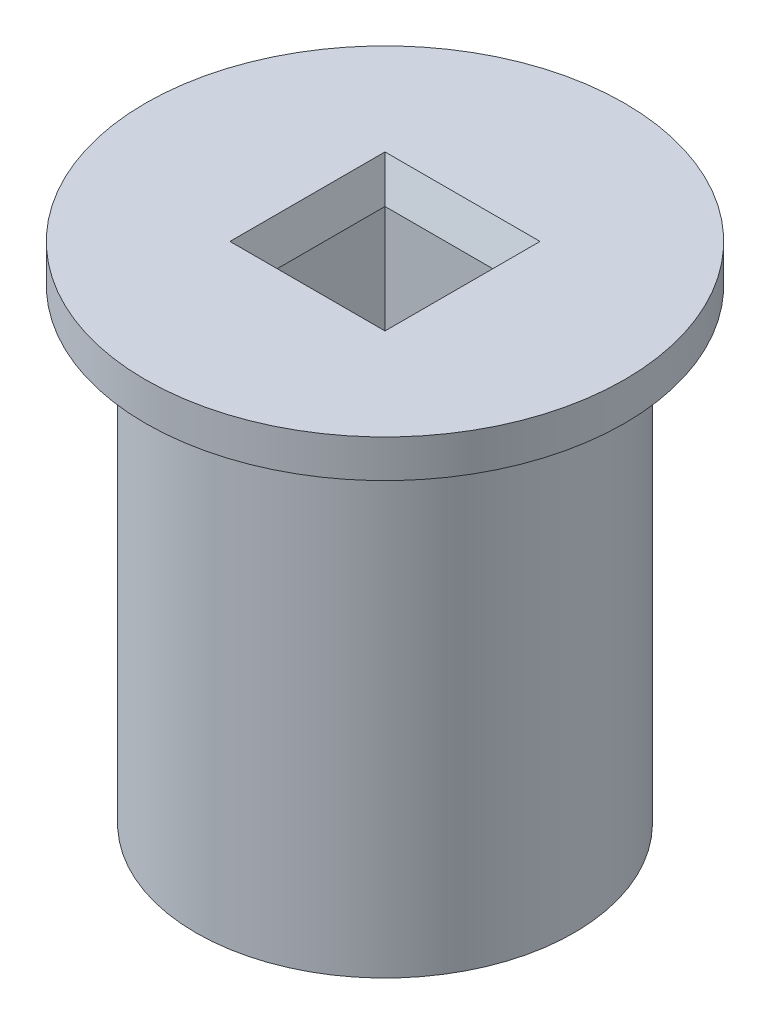
from build123d import *

# Parameters (mm, degrees)
SKETCH_1_R          = 15
SKETCH_1_W          = 10.3
SKETCH_1_H          = 10.3
EXTRUDE_1_DEPTH     = 40
SKETCH1_R           = 19
SKETCH1_W           = 10.3
SKETCH1_H           = 10.3
BOSS_EXTRUDE1_DEPTH = 3
CHAMFER1_SIZE       = 1
CHAMFER1_SIZE2      = 2.747477419


with BuildPart() as part:
    # Эскиз1 → Бобышка-Вытянуть1 (new body)
    with BuildSketch(Plane(origin=(0, 0, 0), x_dir=(1, 0, 0), z_dir=(0, 1, 0))):
        Circle(SKETCH_1_R)
        Rectangle(SKETCH_1_W, SKETCH_1_H, mode=Mode.SUBTRACT)
    extrude(amount=EXTRUDE_1_DEPTH)

    # Sketch1 → Boss-Extrude1 (add)
    with BuildSketch(Plane(origin=(0, 40, 0), x_dir=(1, 0, 0), z_dir=(0, 1, 0))):
        Circle(SKETCH1_R)
        Rectangle(SKETCH1_W, SKETCH1_H, mode=Mode.SUBTRACT)
    extrude(amount=-BOSS_EXTRUDE1_DEPTH)

    # Chamfer1
    chamfer1_edges = [part.edges().sort_by_distance(p)[0] for p in [
        (0, 40, -5.15),
        (-5.15, 40, 0),
        (0, 40, 5.15),
        (5.15, 40, 0),
    ]]
    chamfer1_side = [part.faces().sort_by_distance(p)[0] for p in [
        (-18.462598846, 40, 0),
    ]]
    chamfer(chamfer1_edges, length=CHAMFER1_SIZE, length2=CHAMFER1_SIZE2, reference=chamfer1_side[0])


solid = part.part
